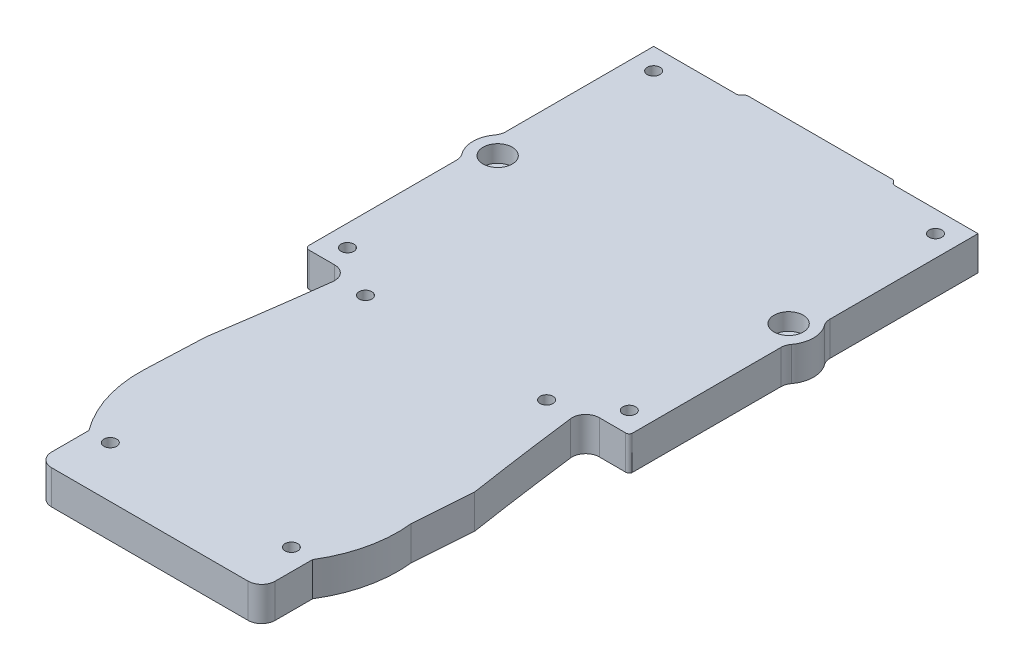
from build123d import *

# Parameters (mm, degrees)
SKETCH1_R           = 1.190625
BOSS_EXTRUDE1_DEPTH = 6.35
SKETCH2_R           = 1.190625
CUT_EXTRUDE1_DEPTH  = 5.953125
SKETCH3_R           = 2.728515752
CUT_EXTRUDE2_DEPTH  = 3.175


with BuildPart() as part:
    # Sketch1 → Boss-Extrude1 (new body)
    with BuildSketch(Plane(origin=(0, 0, 0), x_dir=(1, 0, 0), z_dir=(0, 1, 0))):
        with BuildLine():
            ThreePointArc((57.271558663, 87.137426409), (57.399480252, 86.341513261), (57.770360032, 85.625768991))
            ThreePointArc((57.770360032, 85.625768991), (58.78527106, 82.55), (57.770360032, 79.474231009))
            ThreePointArc((57.770360032, 79.474231009), (57.399480252, 78.758486739), (57.271558663, 77.962573591))
            Line((57.271558663, 77.962573591), (57.271558663, 50.187158197))
            ThreePointArc((57.271558663, 50.187158197), (57.006550783, 49.778004586), (56.529846621, 49.676078162))
            Line((56.529846621, 49.676078162), (52.561739328, 49.676078162))
            Line((52.561739328, 49.676078162), (51.683486492, 49.676078162))
            ThreePointArc((51.683486492, 49.676078162), (49.779800182, 48.817618657), (49.162915139, 46.822517874))
            ThreePointArc((49.162915139, 46.822517874), (50.534142833, 36.419600029), (52.056928392, 26.037784715))
            Line((52.056928392, 26.037784715), (51.254736023, 14.952744828))
            ThreePointArc((51.254736023, 14.952744828), (50.812383961, 7.190984278), (47.857667851, 0))
            Line((47.857667851, 0), (47.857667851, -6.985))
            ThreePointArc((47.857667851, -6.985), (47.113719075, -8.781051224), (45.317667851, -9.525))
            Line((45.317667851, -9.525), (8.657332149, -9.525))
            ThreePointArc((8.657332149, -9.525), (6.861280925, -8.781051224), (6.117332149, -6.985))
            Line((6.117332149, -6.985), (6.117332149, 0))
            ThreePointArc((6.117332149, 0), (2.495961134, 7.074805948), (1.444635194, 14.952744828))
            Line((1.444635194, 14.952744828), (1.918071608, 26.037784715))
            ThreePointArc((1.918071608, 26.037784715), (3.440857167, 36.419600029), (4.812084861, 46.822517874))
            ThreePointArc((4.812084861, 46.822517874), (4.195199818, 48.817618657), (2.291513508, 49.676078162))
            Line((2.291513508, 49.676078162), (-2.470986492, 49.676078162))
            ThreePointArc((-2.470986492, 49.676078162), (-3.032252499, 49.908562155), (-3.264736492, 50.469828162))
            Line((-3.264736492, 50.469828162), (-3.264736492, 77.962573591))
            ThreePointArc((-3.264736492, 77.962573591), (-3.392658081, 78.758486739), (-3.763537861, 79.474231009))
            ThreePointArc((-3.763537861, 79.474231009), (-4.778448889, 82.55), (-3.763537861, 85.625768991))
            ThreePointArc((-3.763537861, 85.625768991), (-3.392658081, 86.341513261), (-3.264736492, 87.137426409))
            Line((-3.264736492, 87.137426409), (-3.264736492, 114.763578162))
            Line((-3.264736492, 114.763578162), (12.197441337, 114.763578162))
            ThreePointArc((12.197441337, 114.763578162), (12.594316337, 114.869920498), (12.884849002, 115.160453162))
            ThreePointArc((12.884849002, 115.160453162), (13.175381666, 115.450985826), (13.572256666, 115.557328162))
            Line((13.572256666, 115.557328162), (40.402743334, 115.557328162))
            ThreePointArc((40.402743334, 115.557328162), (40.799618334, 115.450985826), (41.090150998, 115.160453162))
            ThreePointArc((41.090150998, 115.160453162), (41.380683663, 114.869920498), (41.777558663, 114.763578162))
            Line((41.777558663, 114.763578162), (57.271558663, 114.763578162))
            Line((57.271558663, 114.763578162), (57.271558663, 87.137426409))
        make_face()
        with Locations((54.141854512, 82.55)):
            Circle(SKETCH1_R, mode=Mode.SUBTRACT)
        with Locations((-0.166854512, 82.55)):
            Circle(SKETCH1_R, mode=Mode.SUBTRACT)
    extrude(amount=BOSS_EXTRUDE1_DEPTH)

    # Sketch2 → Cut-Extrude1 (cut)
    with BuildSketch(Plane(origin=(0, 6.35, 0), x_dir=(1, 0, 0), z_dir=(0, 1, 0))):
        with Locations((10.086082149, 0)):
            Circle(SKETCH2_R)
        with Locations((43.888917851, 0)):
            Circle(SKETCH2_R)
        with Locations((10.086082149, 47.625)):
            Circle(SKETCH2_R)
        with Locations((43.888917851, 47.625)):
            Circle(SKETCH2_R)
        with Locations((0.704013508, 53.644828162)):
            Circle(SKETCH2_R)
        with Locations((0.704013508, 110.794828162)):
            Circle(SKETCH2_R)
        with Locations((53.302808663, 53.644828162)):
            Circle(SKETCH2_R)
        with Locations((53.302808663, 110.794828162)):
            Circle(SKETCH2_R)
    extrude(amount=-CUT_EXTRUDE1_DEPTH, mode=Mode.SUBTRACT)

    # Sketch3 → Cut-Extrude2 (cut)
    with BuildSketch(Plane(origin=(0, 6.35, 0), x_dir=(1, 0, 0), z_dir=(0, 1, 0))):
        with Locations((-0.166854512, 82.55)):
            Circle(SKETCH3_R)
        with Locations((54.141854512, 82.55)):
            Circle(SKETCH3_R)
    extrude(amount=-CUT_EXTRUDE2_DEPTH, mode=Mode.SUBTRACT)


solid = part.part
